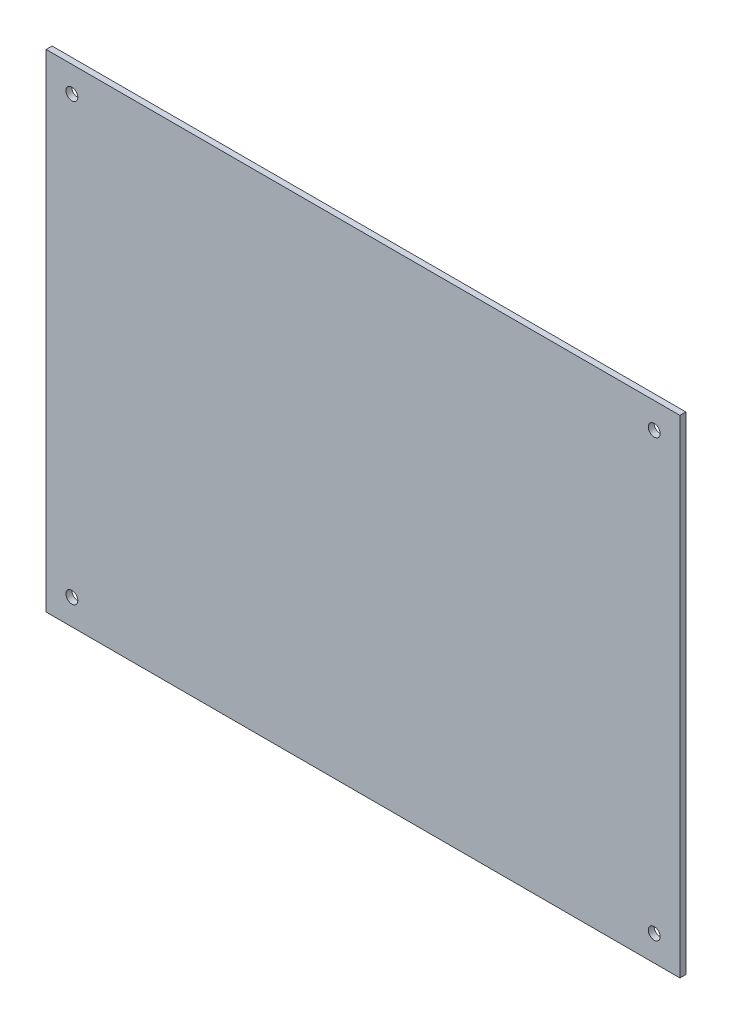
from build123d import *

# Parameters (mm, degrees)
SKETCH_1_W      = 1600
SKETCH_1_H      = 1230
SKETCH_1_R      = 15
EXTRUDE_1_DEPTH = 3
SCALE_1_SCALE_X = 0.1
SCALE_1_SCALE_Y = 0.1
SCALE_1_SCALE_Z = 0.5


with BuildPart() as part:
    # 草图1 → 凸台-拉伸1 (new body)
    with BuildSketch(Plane.XY):
        with Locations((1152.60835314, -1687.80288964)):
            Rectangle(SKETCH_1_W, SKETCH_1_H)
        with Locations((417.60835314, -1137.80288964)):
            Circle(SKETCH_1_R, mode=Mode.SUBTRACT)
        with Locations((1887.60835314, -1137.80288964)):
            Circle(SKETCH_1_R, mode=Mode.SUBTRACT)
        with Locations((1887.60835314, -2237.80288964)):
            Circle(SKETCH_1_R, mode=Mode.SUBTRACT)
        with Locations((417.60835314, -2237.80288964)):
            Circle(SKETCH_1_R, mode=Mode.SUBTRACT)
    extrude(amount=EXTRUDE_1_DEPTH)


with BuildPart() as part_1:
    # 缩放比例1: scaled about (1152.60835314, -1687.80288964, 1.5)
    add(part.part.scale((SCALE_1_SCALE_X, SCALE_1_SCALE_Y, SCALE_1_SCALE_Z), about=(1152.60835314, -1687.80288964, 1.5)))


solid = part_1.part
